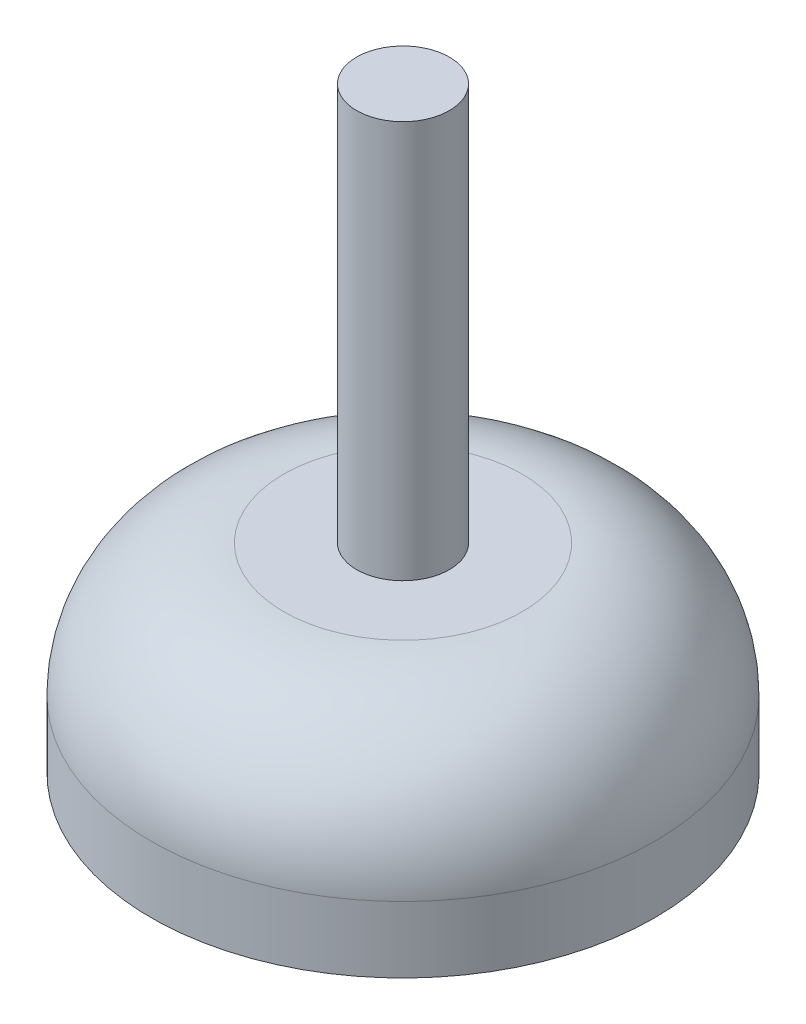
from build123d import *

# Parameters (mm, degrees)
CONG_1_R = 10


with BuildPart() as part:
    # Esquisse1 → Révolution1 (revolve)
    with BuildSketch(Plane.XY):
        Polygon((0, 0), (0, -45), (-19, -45), (-19, -30), (-3.5, -30), (-3.5, 0), align=None)
    revolve(axis=Axis((0, 0, 0), (0, -1, 0)))

    # Congé1
    cong_1_edges = [part.edges().sort_by_distance(p)[0] for p in [
        (19, -30, 0),
    ]]
    fillet(cong_1_edges, radius=CONG_1_R)


solid = part.part
